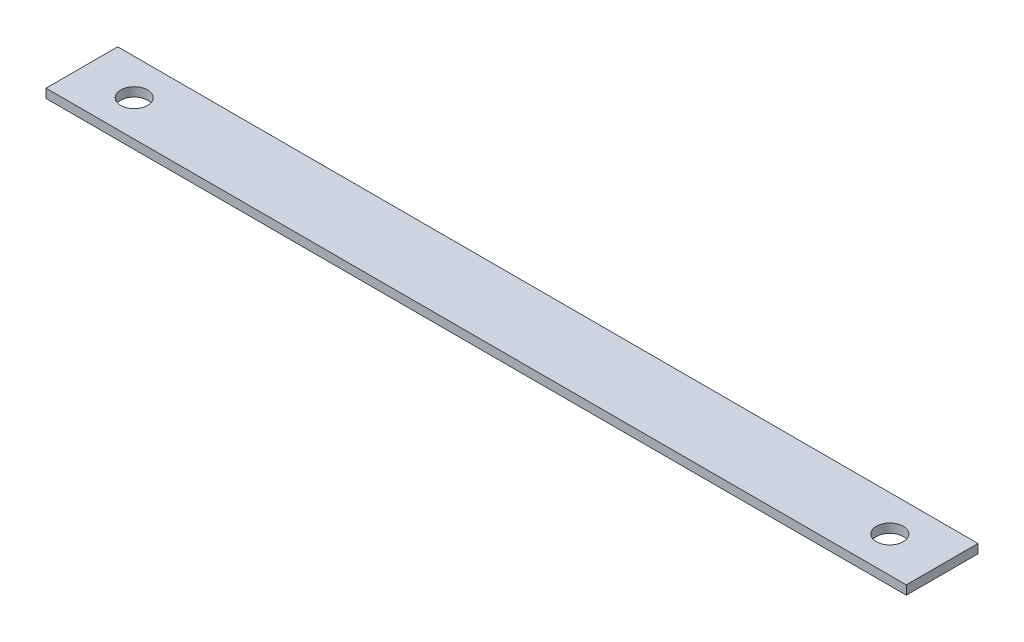
from build123d import *

# Parameters (mm, degrees)
SKETCH1_W           = 304.8
SKETCH1_H           = 25.4
BOSS_EXTRUDE1_DEPTH = 3.175
SKETCH2_R           = 4.7625
CUT_EXTRUDE1_DEPTH  = 4.175


with BuildPart() as part:
    # Sketch1 → Boss-Extrude1 (new body)
    with BuildSketch(Plane(origin=(0, 0, 0), x_dir=(1, 0, 0), z_dir=(0, 1, 0))):
        Rectangle(SKETCH1_W, SKETCH1_H)
    extrude(amount=BOSS_EXTRUDE1_DEPTH)

    # Sketch2 → Cut-Extrude1 (cut, through all)
    with BuildSketch(Plane(origin=(0, 3.175, 0), x_dir=(1, 0, 0), z_dir=(0, 1, 0))):
        with Locations((-133.858, 0)):
            Circle(SKETCH2_R)
        with Locations((133.858, 0)):
            Circle(SKETCH2_R)
    extrude(amount=-CUT_EXTRUDE1_DEPTH, mode=Mode.SUBTRACT)


solid = part.part
